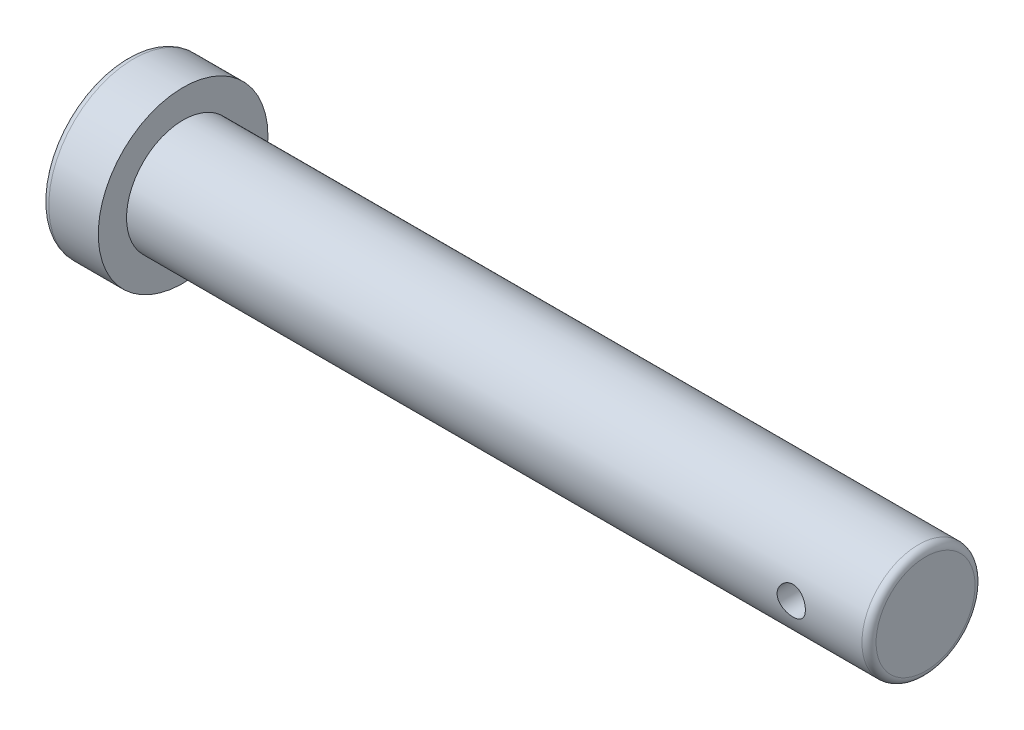
from build123d import *

# Parameters (mm, degrees)
SKETCH2_R           = 12
BOSS_EXTRUDE1_DEPTH = 4
SKETCH3_R           = 8
BOSS_EXTRUDE2_DEPTH = 105
FILLET1_R           = 1
FILLET2_R           = 1
SKETCH4_R           = 2
CUT_EXTRUDE1_DEPTH  = 10


with BuildPart() as part:
    # Sketch2 → Boss-Extrude1 (new body, symmetric)
    with BuildSketch(Plane(origin=(0, 0, 0), x_dir=(0, 0, -1), z_dir=(1, 0, 0))):
        Circle(SKETCH2_R)
    extrude(amount=BOSS_EXTRUDE1_DEPTH, both=True)

    # Sketch3 → Boss-Extrude2 (add)
    with BuildSketch(Plane(origin=(4, 0, 0), x_dir=(0, 0, -1), z_dir=(1, 0, 0))):
        Circle(SKETCH3_R)
    extrude(amount=BOSS_EXTRUDE2_DEPTH)

    # Fillet1
    fillet1_edges = [part.edges().sort_by_distance(p)[0] for p in [
        (-4, 0, 12),
    ]]
    fillet(fillet1_edges, radius=FILLET1_R)

    # Fillet2
    fillet2_edges = [part.edges().sort_by_distance(p)[0] for p in [
        (109, 0, 8),
    ]]
    fillet(fillet2_edges, radius=FILLET2_R)

    # Sketch4 → Cut-Extrude1 (cut, symmetric)
    with BuildSketch(Plane.XY):
        with Locations((98, 0)):
            Circle(SKETCH4_R)
    extrude(amount=CUT_EXTRUDE1_DEPTH, both=True, mode=Mode.SUBTRACT)


solid = part.part
